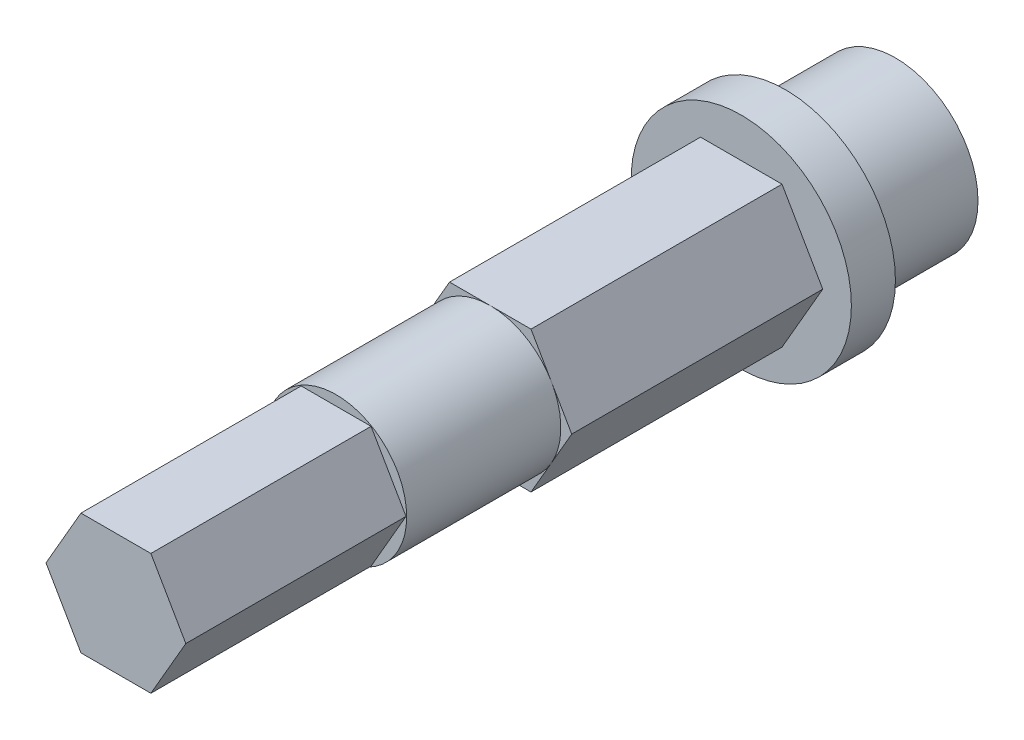
from build123d import *

# Parameters (mm, degrees)
SKETCH1_R           = 3.75
BOSS_EXTRUDE1_DEPTH = 5
SKETCH2_R           = 5
BOSS_EXTRUDE2_DEPTH = 2
BOSS_EXTRUDE3_DEPTH = 11.4
SKETCH4_R           = 3.204293994
BOSS_EXTRUDE4_DEPTH = 7
BOSS_EXTRUDE5_DEPTH = 10


with BuildPart() as part:
    # Sketch1 → Boss-Extrude1 (new body)
    with BuildSketch(Plane.XY):
        Circle(SKETCH1_R)
    extrude(amount=BOSS_EXTRUDE1_DEPTH)

    # Sketch2 → Boss-Extrude2 (add)
    with BuildSketch(Plane.XY.offset(5)):
        Circle(SKETCH2_R)
    extrude(amount=BOSS_EXTRUDE2_DEPTH)

    # Sketch3 → Boss-Extrude3 (add)
    with BuildSketch(Plane.XY.offset(7)):
        Polygon((3.7, 0), (1.85, 3.204293994), (-1.85, 3.204293994), (-3.7, 0), (-1.85, -3.204293994), (1.85, -3.204293994), align=None)
    extrude(amount=BOSS_EXTRUDE3_DEPTH)

    # Sketch4 → Boss-Extrude4 (add)
    with BuildSketch(Plane.XY.offset(18.4)):
        Circle(SKETCH4_R)
    extrude(amount=BOSS_EXTRUDE4_DEPTH)

    # Sketch5 → Boss-Extrude5 (add)
    with BuildSketch(Plane.XY.offset(25.4)):
        Polygon((3.175, 0), (1.5875, 2.749630657), (-1.5875, 2.749630657), (-3.175, 0), (-1.5875, -2.749630657), (1.5875, -2.749630657), align=None)
    extrude(amount=BOSS_EXTRUDE5_DEPTH)


solid = part.part
